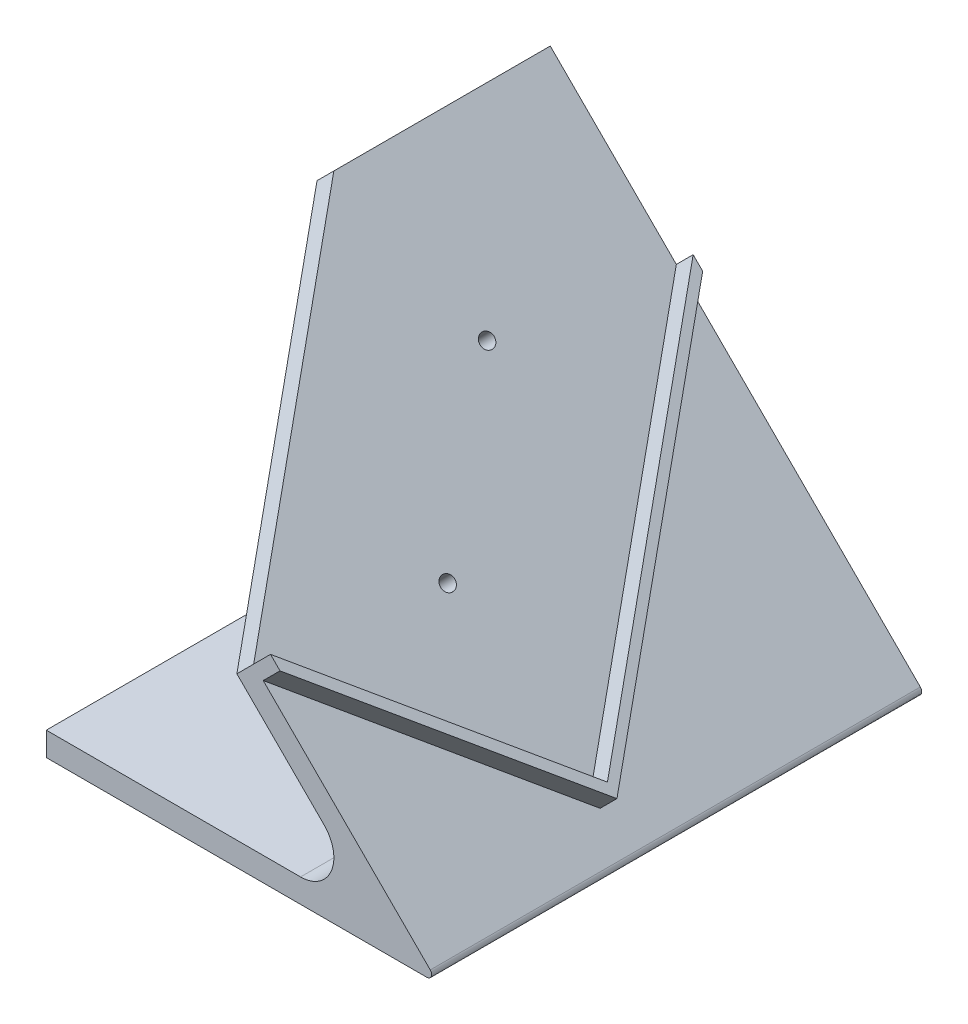
from build123d import *

# Parameters (mm, degrees)
BOSS_EXTRUDE1_DEPTH       = 103
BOSS_EXTRUDE2_DEPTH       = 5
CUT_EXTRUDE1_DEPTH        = 120.616052434
CUT_EXTRUDE1_DEPTH_BACK   = 5
M5_CLEARANCE_HOLE1_REACH  = 162.532
M5_CLEARANCE_HOLE1_BORE_R = 1.5


with BuildPart() as part:
    # Sketch1 → Boss-Extrude1 (new body)
    with BuildSketch(Plane.XY):
        with BuildLine():
            Line((2.925360851, 74.488852712), (80.707106781, -3.292893219))
            ThreePointArc((80.707106781, -3.292893219), (80.923879533, -4.382683432), (80, -5))
            Line((80, -5), (0, -5))
            Line((0, -5), (0, 0))
            Line((0, 0), (53.443650814, 0))
            ThreePointArc((53.443650814, 0), (59.910807541, 4.321215973), (58.393398282, 11.949747468))
            Line((58.393398282, 11.949747468), (-0.610173055, 70.953318806))
            Line((-0.610173055, 70.953318806), (2.925360851, 74.488852712))
        make_face()
    extrude(amount=BOSS_EXTRUDE1_DEPTH)

    # Sketch2 → Boss-Extrude2 (add)
    with BuildSketch(Plane(origin=(38.707106781, 38.707106781, 0), x_dir=(0, 0, -1), z_dir=(0.7071067811865487, 0.7071067811865465, 0))):
        Polygon((-61.518289963, -48.391918986), (-100.409162928, -9.501046021), (-103, -6.910208949), (-103, -9.738636074), (-61.518289963, -51.220346111), (0, 10.297943853), (0, 13.126370977), (-1.414213562, 11.712157415), align=None)
    extrude(amount=BOSS_EXTRUDE2_DEPTH)

    # Sketch4 → Cut-Extrude1 (cut, two sides)
    with BuildSketch(Plane(origin=(38.707106781, 38.707106781, 0), x_dir=(0, 0, -1), z_dir=(0.7071067811865487, 0.7071067811865465, 0))) as cut_extrude1_sk:
        Polygon((-287.389423781, -191.29963273), (-103, -6.910208949), (-45.486760671, 50.60303038), (138.902663111, 234.992454162), (-229.876184452, 603.771301725), (-656.168271344, 177.479214832), align=None)
    extrude(amount=CUT_EXTRUDE1_DEPTH, mode=Mode.SUBTRACT)
    extrude(cut_extrude1_sk.sketch, amount=-CUT_EXTRUDE1_DEPTH_BACK, mode=Mode.SUBTRACT)

    # M5 Clearance Hole1 bore → M5 Clearance Hole1 (cut, up to next)
    with BuildSketch(Plane(origin=(80.628758112, -3.214544549, 114.598480766), x_dir=(-0.4999999999999967, 0.4999999999999984, 0.707106781186551), z_dir=(0.7071067811865487, 0.7071067811865464, 0)), mode=Mode.PRIVATE) as m5_clearance_hole1_sk1:
        with Locations((-0.829965603, -69.236760125)):
            Circle(M5_CLEARANCE_HOLE1_BORE_R)
    m5_clearance_hole1_tool1 = extrude(m5_clearance_hole1_sk1.sketch, amount=-M5_CLEARANCE_HOLE1_REACH, mode=Mode.PRIVATE) & part.part
    # M5 Clearance Hole1 bore → M5 Clearance Hole1 (cut, up to next)
    with BuildSketch(Plane(origin=(80.628758112, -3.214544549, 114.598480766), x_dir=(-0.4999999999999967, 0.4999999999999984, 0.707106781186551), z_dir=(0.7071067811865487, 0.7071067811865464, 0)), mode=Mode.PRIVATE) as m5_clearance_hole1_sk2:
        with Locations((-0.829965603, -109.236760125)):
            Circle(M5_CLEARANCE_HOLE1_BORE_R)
    m5_clearance_hole1_tool2 = extrude(m5_clearance_hole1_sk2.sketch, amount=-M5_CLEARANCE_HOLE1_REACH, mode=Mode.PRIVATE) & part.part
    add(m5_clearance_hole1_tool1.solids().sort_by_distance((46.425361, 30.988853, 65.053824))[0], mode=Mode.SUBTRACT)
    add(m5_clearance_hole1_tool2.solids().sort_by_distance((26.425361, 50.988853, 36.769553))[0], mode=Mode.SUBTRACT)


solid = part.part
